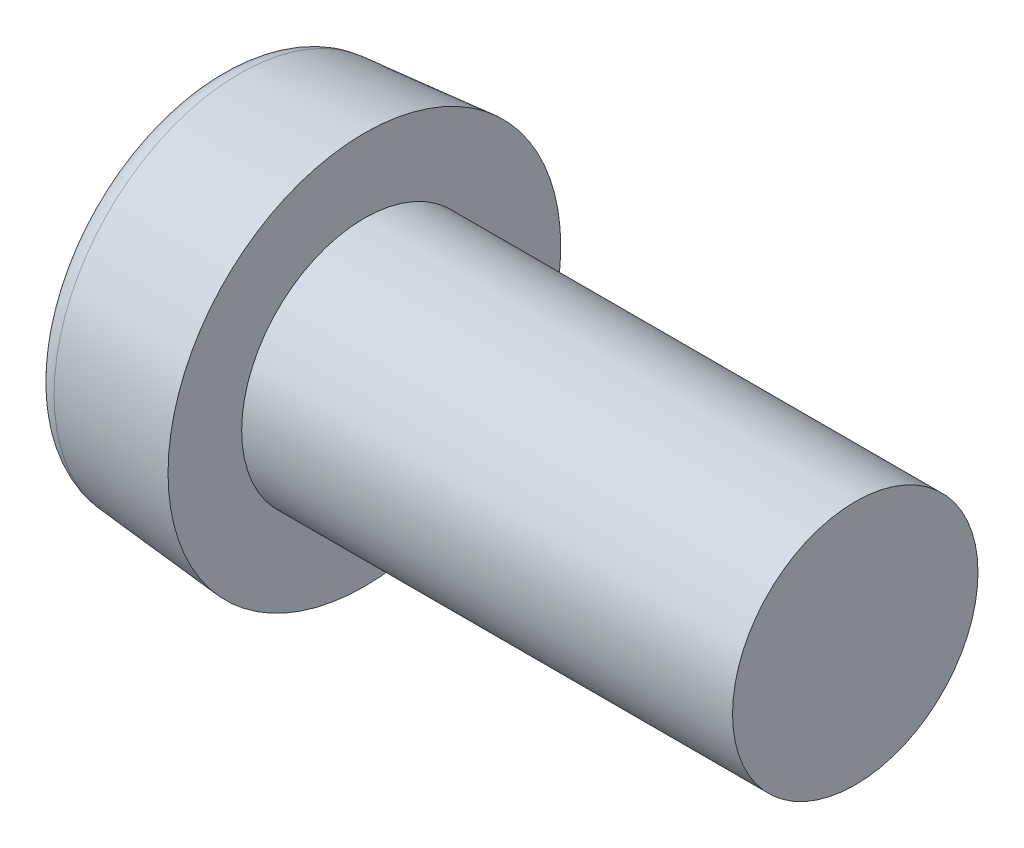
from build123d import *

# Parameters (mm, degrees)
SKETCH1_R      = 8
BASEHEAD_DEPTH = 6
BASEHEAD_DRAFT = -5
SKETCH8_W      = 20
SKETCH8_H      = 5
SOCKET_DEPTH   = 3
HEADFILLET2_R  = 1


with BuildPart() as part:
    # Sketch1 → BaseHead (with draft: the straight prism first)
    with BuildSketch(Plane(origin=(6, 0, 0), x_dir=(0, 0, -1), z_dir=(1, 0, 0))):
        Circle(SKETCH1_R)
    extrude(amount=-BASEHEAD_DEPTH)
    # BaseHead: the draft: its side faces are tilted about the plane it starts from
    basehead_sides = [part.faces().sort_by_distance(p)[0] for p in [
        (3, 0, 8),
    ]]
    draft(basehead_sides, Plane(origin=(6, 0, 0), x_dir=(0, 0, -1), z_dir=(1, 0, 0)), BASEHEAD_DRAFT)

    # Sketch8 → Revolve1 (revolve)
    with BuildSketch(Plane.XY, mode=Mode.PRIVATE) as revolve1_sk:
        with Locations((16, 2.5)):
            Rectangle(SKETCH8_W, SKETCH8_H)
    revolve(revolve1_sk.sketch.rotate(Axis((0, 0, 0), (1, 0, 0)), 90), axis=Axis((0, 0, 0), (1, 0, 0)))

    # Sketch4 → Socket (cut)
    with BuildSketch(Plane(origin=(0, 0, 0), x_dir=(0, 0, -1), z_dir=(1, 0, 0))):
        with BuildLine():
            add(Edge.make_bspline(
                [(1.655, 2.866544087), (2.291538462, 2.499038434), (3.819230769, 2.205033913), (3.055384615, 0), (3.819230769, -2.205033913), (1.527692308, -2.646040695), (0, -4.410067825), (-1.527692308, -2.646040695), (-3.819230769, -2.205033913), (-3.055384615, 0), (-3.819230769, 2.205033913), (-1.527692308, 2.646040695), (0, 4.410067825), (1.018461538, 3.234049739), (1.655, 2.866544087)],
                knots=[0, 0, 0, 0, 0.083333333, 0.166666667, 0.25, 0.333333333, 0.416666667, 0.5, 0.583333333, 0.666666667, 0.75, 0.833333333, 0.916666667, 1, 1, 1, 1], degree=3))
        make_face()
    extrude(amount=SOCKET_DEPTH, mode=Mode.SUBTRACT)

    # Sketch5 → Cut-Loft1 section 0
    with BuildSketch(Plane.ZY.offset(-3), mode=Mode.PRIVATE) as cut_loft1_s0:
        with BuildLine():
            add(Edge.make_bspline(
                [(-1.655, 2.866544087), (-2.291538462, 2.499038434), (-3.819230769, 2.205033913), (-3.055384615, 0), (-3.819230769, -2.205033913), (-1.527692308, -2.646040695), (0, -4.410067825), (1.527692308, -2.646040695), (3.819230769, -2.205033913), (3.055384615, 0), (3.819230769, 2.205033913), (1.527692308, 2.646040695), (0, 4.410067825), (-1.018461538, 3.234049739), (-1.655, 2.866544087)],
                knots=[0, 0, 0, 0, 0.083333333, 0.166666667, 0.25, 0.333333333, 0.416666667, 0.5, 0.583333333, 0.666666667, 0.75, 0.833333333, 0.916666667, 1, 1, 1, 1], degree=3))
        make_face()
    loft([Vertex(4, 0, 0), cut_loft1_s0.sketch], mode=Mode.SUBTRACT)

    # HeadFillet2
    headfillet2_edges = [part.edges().sort_by_distance(p)[0] for p in [
        (0, 0, 7.475068019),
    ]]
    fillet(headfillet2_edges, radius=HEADFILLET2_R)


solid = part.part
